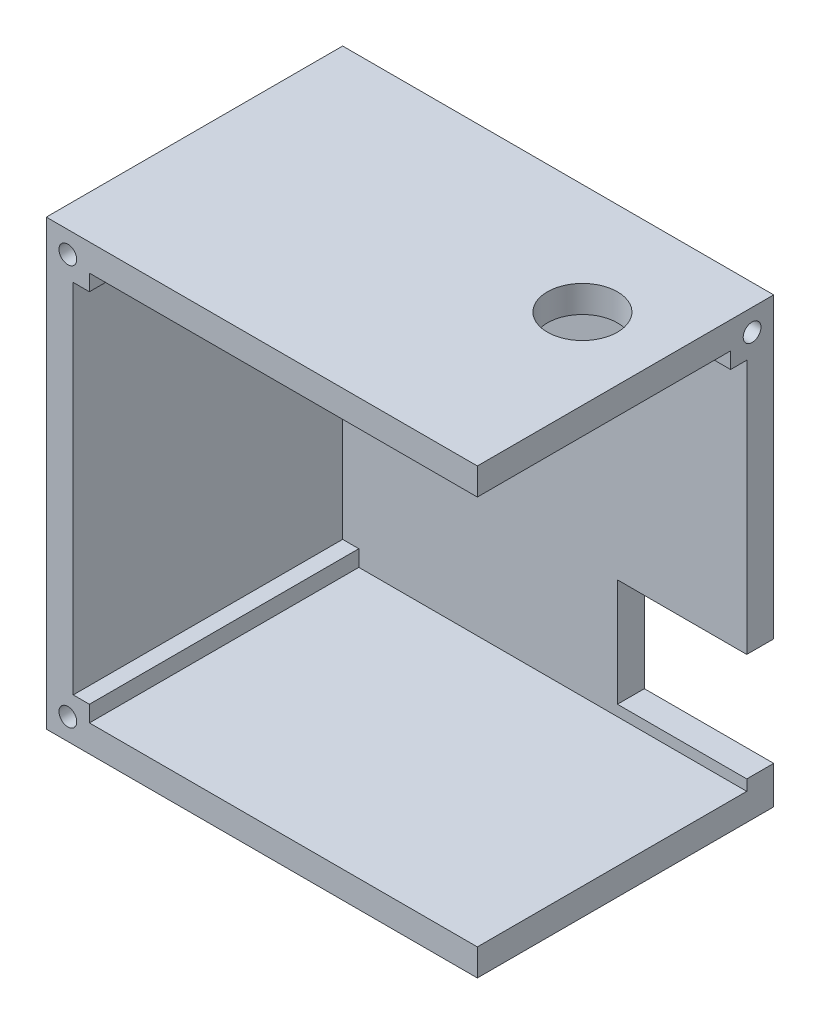
from build123d import *

# Parameters (mm, degrees)
SKETCH1_W           = 80
SKETCH1_H           = 82.3
BOSS_EXTRUDE1_DEPTH = 55
CUT_EXTRUDE1_DEPTH  = 50
SKETCH3_R           = 1.65
CUT_EXTRUDE2_DEPTH  = 25
SKETCH4_W           = 15
SKETCH4_H           = 27
SKETCH4_W_2         = 24
SKETCH4_H_2         = 20
CUT_EXTRUDE3_DEPTH  = 20
SKETCH6_R           = 6.5
CUT_EXTRUDE4_DEPTH  = 20
SKETCH7_W           = 3
SKETCH7_H           = 3
BOSS_EXTRUDE2_DEPTH = 30
SKETCH8_R           = 1.65
CUT_EXTRUDE5_DEPTH  = 25


with BuildPart() as part:
    # Sketch1 → Boss-Extrude1 (new body)
    with BuildSketch(Plane.XY):
        with Locations((40, 41.15)):
            Rectangle(SKETCH1_W, SKETCH1_H)
    extrude(amount=BOSS_EXTRUDE1_DEPTH)

    # Sketch2 → Cut-Extrude1 (cut)
    with BuildSketch(Plane.XY.offset(55)):
        Polygon((80, 5), (80, 77.3), (8, 77.3), (8, 74.3), (5, 74.3), (5, 8), (8, 8), (8, 5), align=None)
    extrude(amount=-CUT_EXTRUDE1_DEPTH, mode=Mode.SUBTRACT)

    # Sketch3 → Cut-Extrude2 (cut)
    with BuildSketch(Plane.XY.offset(55)):
        with Locations((4, 78.3)):
            Circle(SKETCH3_R)
        with Locations((4, 4)):
            Circle(SKETCH3_R)
    extrude(amount=-CUT_EXTRUDE2_DEPTH, mode=Mode.SUBTRACT)

    # Sketch4 → Cut-Extrude3 (cut)
    with BuildSketch(Plane.XY.offset(5)):
        with Locations((18, 41.15)):
            Rectangle(SKETCH4_W, SKETCH4_H)
        with Locations((68, 17)):
            Rectangle(SKETCH4_W_2, SKETCH4_H_2)
    extrude(amount=-CUT_EXTRUDE3_DEPTH, mode=Mode.SUBTRACT)

    # Sketch6 → Cut-Extrude4 (cut)
    with BuildSketch(Plane.XZ.offset(-77.3)):
        with Locations((65, 20.5)):
            Circle(SKETCH6_R)
    extrude(amount=-CUT_EXTRUDE4_DEPTH, mode=Mode.SUBTRACT)

    # Sketch7 → Boss-Extrude2 (add)
    with BuildSketch(Plane(origin=(80, 0, 0), x_dir=(0, 0, -1), z_dir=(1, 0, 0))):
        with Locations((-6.5, 75.8)):
            Rectangle(SKETCH7_W, SKETCH7_H)
    extrude(amount=-BOSS_EXTRUDE2_DEPTH)

    # Sketch8 → Cut-Extrude5 (cut)
    with BuildSketch(Plane(origin=(80, 0, 0), x_dir=(0, 0, -1), z_dir=(1, 0, 0))):
        with Locations((-4.004640203, 78.3)):
            Circle(SKETCH8_R)
    extrude(amount=-CUT_EXTRUDE5_DEPTH, mode=Mode.SUBTRACT)


solid = part.part
